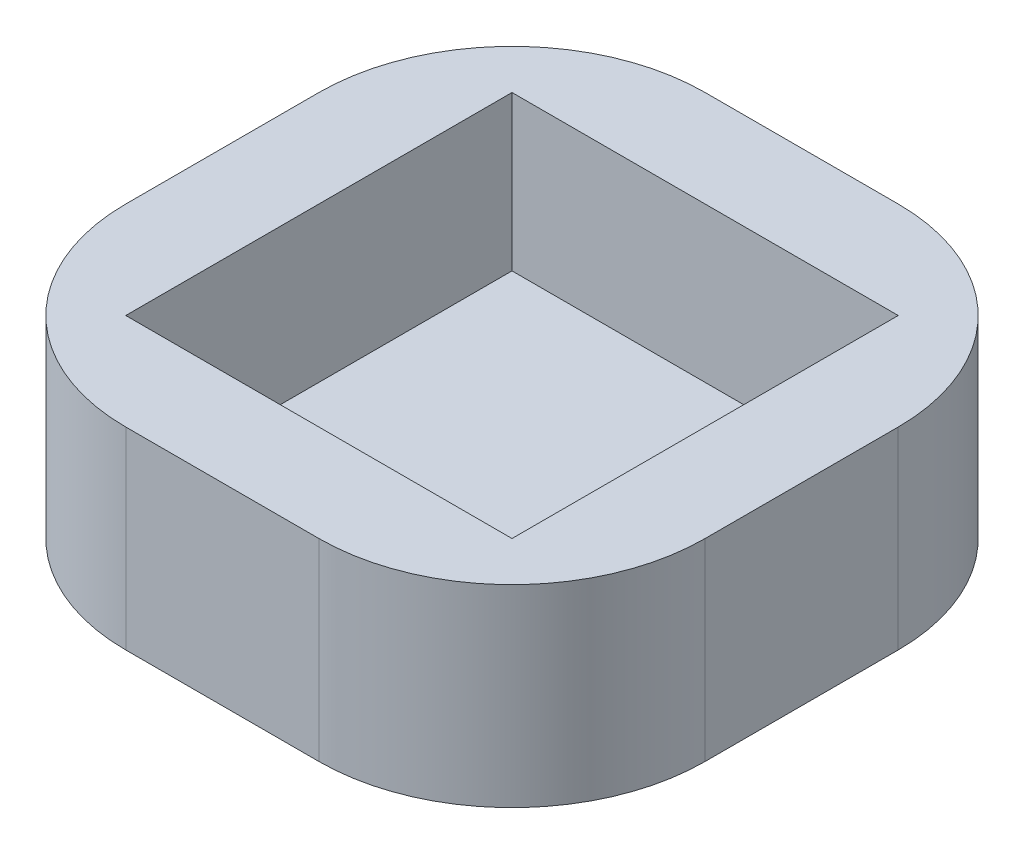
from build123d import *

# Parameters (mm, degrees)
BOSS_EXTRUDE1_DEPTH = 10
SKETCH2_W           = 20
SKETCH2_H           = 20
CUT_EXTRUDE1_DEPTH  = 8


with BuildPart() as part:
    # Sketch1 → Boss-Extrude1 (new body)
    with BuildSketch(Plane(origin=(0, 0, 0), x_dir=(1, 0, 0), z_dir=(0, 1, 0))):
        with BuildLine():
            Line((-26.392104515, 9.350576585), (-16.392104515, 9.350576585))
            ThreePointArc((-16.392104515, 9.350576585), (-9.321036703, 6.421644397), (-6.392104515, -0.649423415))
            Line((-6.392104515, -0.649423415), (-6.392104515, -10.649423415))
            ThreePointArc((-6.392104515, -10.649423415), (-9.321036703, -17.720491227), (-16.392104515, -20.649423415))
            Line((-16.392104515, -20.649423415), (-26.392104515, -20.649423415))
            ThreePointArc((-26.392104515, -20.649423415), (-33.463172327, -17.720491227), (-36.392104515, -10.649423415))
            Line((-36.392104515, -10.649423415), (-36.392104515, -0.649423415))
            ThreePointArc((-36.392104515, -0.649423415), (-33.463172327, 6.421644397), (-26.392104515, 9.350576585))
        make_face()
    extrude(amount=BOSS_EXTRUDE1_DEPTH)

    # Sketch2 → Cut-Extrude1 (cut)
    with BuildSketch(Plane(origin=(0, 10, 0), x_dir=(-1, 0, 0), z_dir=(0, 1, 0))):
        with Locations((21.392104515, 5.649423415)):
            Rectangle(SKETCH2_W, SKETCH2_H)
    extrude(amount=-CUT_EXTRUDE1_DEPTH, mode=Mode.SUBTRACT)


solid = part.part
